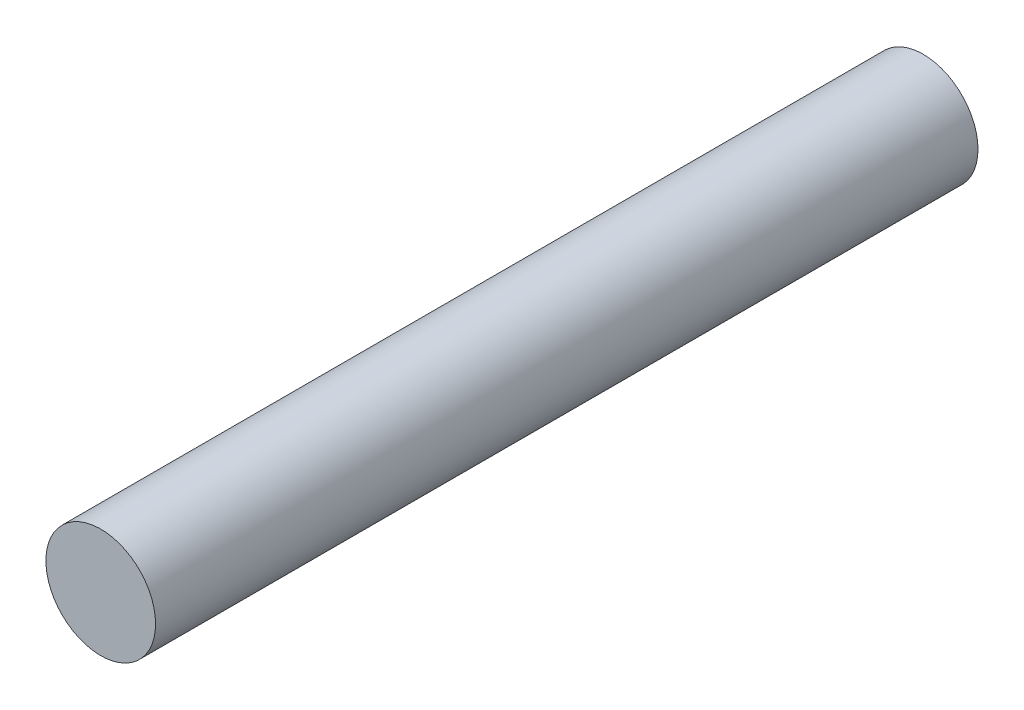
from build123d import *

# Parameters (mm, degrees)
SKETCH1_R           = 2.54
BOSS_EXTRUDE1_DEPTH = 38.1


with BuildPart() as part:
    # Sketch1 → Boss-Extrude1 (new body)
    with BuildSketch(Plane.XY):
        Circle(SKETCH1_R)
    extrude(amount=BOSS_EXTRUDE1_DEPTH)


solid = part.part
